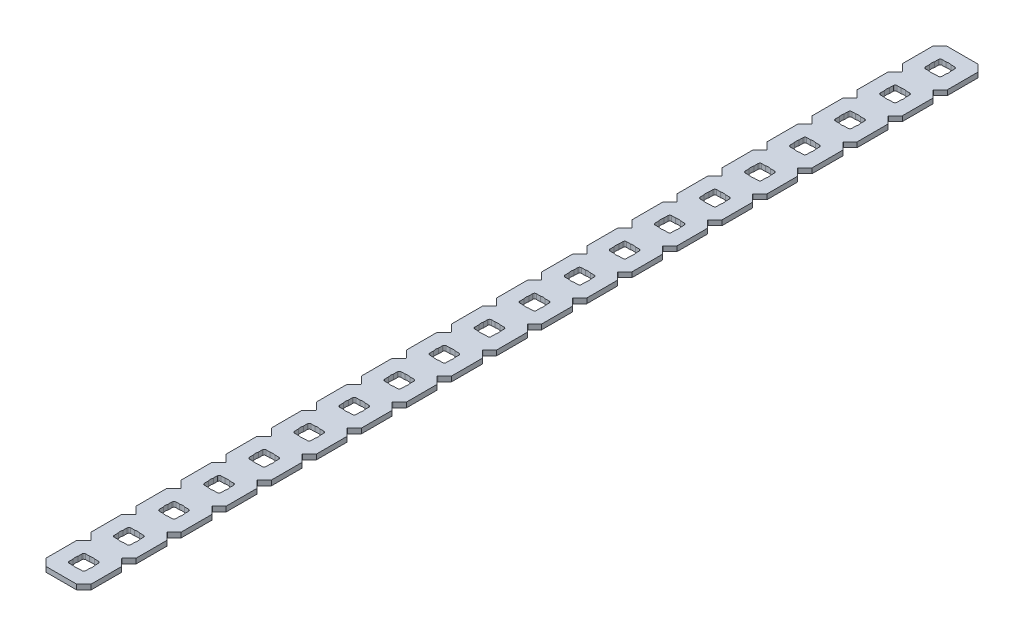
from build123d import *

# Parameters (mm, degrees)
BOSS_EXTRUDE1_DEPTH = 1.4224
SKETCH2_R           = 2.413
CUT_EXTRUDE1_DEPTH  = 2.54
LPATTERN1_COUNT     = 25
LPATTERN1_PITCH     = 12.7
SKETCH3_W           = 12.7
SKETCH3_H           = 63.589802561
CUT_EXTRUDE2_DEPTH  = 2.4224


with BuildPart() as part:
    # Sketch1 → Boss-Extrude1 (new body)
    with BuildSketch(Plane.XZ):
        with BuildLine():
            Line((12.7, -302.773014945), (12.7, -294.126985055))
            Line((12.7, -294.126985055), (10.762817506, -292.189802561))
            ThreePointArc((10.762817506, -292.189802561), (10.725620068, -292.1), (10.762817506, -292.010197439))
            Line((10.762817506, -292.010197439), (12.7, -290.073014945))
            Line((12.7, -290.073014945), (12.7, -281.426985055))
            Line((12.7, -281.426985055), (10.762817506, -279.489802561))
            ThreePointArc((10.762817506, -279.489802561), (10.725620068, -279.4), (10.762817506, -279.310197439))
            Line((10.762817506, -279.310197439), (12.7, -277.373014945))
            Line((12.7, -277.373014945), (12.7, -268.726985055))
            Line((12.7, -268.726985055), (10.762817506, -266.789802561))
            ThreePointArc((10.762817506, -266.789802561), (10.725620068, -266.7), (10.762817506, -266.610197439))
            Line((10.762817506, -266.610197439), (12.7, -264.673014945))
            Line((12.7, -264.673014945), (12.7, -256.026985055))
            Line((12.7, -256.026985055), (10.762817506, -254.089802561))
            ThreePointArc((10.762817506, -254.089802561), (10.725620068, -254), (10.762817506, -253.910197439))
            Line((10.762817506, -253.910197439), (12.7, -251.973014945))
            Line((12.7, -251.973014945), (12.7, -243.326985055))
            Line((12.7, -243.326985055), (10.762817506, -241.389802561))
            ThreePointArc((10.762817506, -241.389802561), (10.725620068, -241.3), (10.762817506, -241.210197439))
            Line((10.762817506, -241.210197439), (12.7, -239.273014945))
            Line((12.7, -239.273014945), (12.7, -230.626985055))
            Line((12.7, -230.626985055), (10.762817506, -228.689802561))
            ThreePointArc((10.762817506, -228.689802561), (10.725620068, -228.6), (10.762817506, -228.510197439))
            Line((10.762817506, -228.510197439), (12.7, -226.573014945))
            Line((12.7, -226.573014945), (12.7, -217.926985055))
            Line((12.7, -217.926985055), (10.762817506, -215.989802561))
            ThreePointArc((10.762817506, -215.989802561), (10.725620068, -215.9), (10.762817506, -215.810197439))
            Line((10.762817506, -215.810197439), (12.7, -213.873014945))
            Line((12.7, -213.873014945), (12.7, -205.226985055))
            Line((12.7, -205.226985055), (10.762817506, -203.289802561))
            ThreePointArc((10.762817506, -203.289802561), (10.725620068, -203.2), (10.762817506, -203.110197439))
            Line((10.762817506, -203.110197439), (12.7, -201.173014945))
            Line((12.7, -201.173014945), (12.7, -192.526985055))
            Line((12.7, -192.526985055), (10.762817506, -190.589802561))
            ThreePointArc((10.762817506, -190.589802561), (10.725620068, -190.5), (10.762817506, -190.410197439))
            Line((10.762817506, -190.410197439), (12.7, -188.473014945))
            Line((12.7, -188.473014945), (12.7, -179.826985055))
            Line((12.7, -179.826985055), (10.762817506, -177.889802561))
            ThreePointArc((10.762817506, -177.889802561), (10.725620068, -177.8), (10.762817506, -177.710197439))
            Line((10.762817506, -177.710197439), (12.7, -175.773014945))
            Line((12.7, -175.773014945), (12.7, -167.126985055))
            Line((12.7, -167.126985055), (10.762817506, -165.189802561))
            ThreePointArc((10.762817506, -165.189802561), (10.725620068, -165.1), (10.762817506, -165.010197439))
            Line((10.762817506, -165.010197439), (12.7, -163.073014945))
            Line((12.7, -163.073014945), (12.7, -154.426985055))
            Line((12.7, -154.426985055), (10.762817506, -152.489802561))
            ThreePointArc((10.762817506, -152.489802561), (10.725620068, -152.4), (10.762817506, -152.310197439))
            Line((10.762817506, -152.310197439), (12.7, -150.373014945))
            Line((12.7, -150.373014945), (12.7, -141.726985055))
            Line((12.7, -141.726985055), (10.762817506, -139.789802561))
            ThreePointArc((10.762817506, -139.789802561), (10.725620068, -139.7), (10.762817506, -139.610197439))
            Line((10.762817506, -139.610197439), (12.7, -137.673014945))
            Line((12.7, -137.673014945), (12.7, -129.026985055))
            Line((12.7, -129.026985055), (10.762817506, -127.089802561))
            ThreePointArc((10.762817506, -127.089802561), (10.725620068, -127), (10.762817506, -126.910197439))
            Line((10.762817506, -126.910197439), (12.7, -124.973014945))
            Line((12.7, -124.973014945), (12.7, -116.326985055))
            Line((12.7, -116.326985055), (10.762817506, -114.389802561))
            ThreePointArc((10.762817506, -114.389802561), (10.725620068, -114.3), (10.762817506, -114.210197439))
            Line((10.762817506, -114.210197439), (12.7, -112.273014945))
            Line((12.7, -112.273014945), (12.7, -103.626985055))
            Line((12.7, -103.626985055), (10.762817506, -101.689802561))
            ThreePointArc((10.762817506, -101.689802561), (10.725620068, -101.6), (10.762817506, -101.510197439))
            Line((10.762817506, -101.510197439), (12.7, -99.573014945))
            Line((12.7, -99.573014945), (12.7, -90.926985055))
            Line((12.7, -90.926985055), (10.762817506, -88.989802561))
            ThreePointArc((10.762817506, -88.989802561), (10.725620068, -88.9), (10.762817506, -88.810197439))
            Line((10.762817506, -88.810197439), (12.7, -86.873014945))
            Line((12.7, -86.873014945), (12.7, -78.226985055))
            Line((12.7, -78.226985055), (10.762817506, -76.289802561))
            ThreePointArc((10.762817506, -76.289802561), (10.725620068, -76.2), (10.762817506, -76.110197439))
            Line((10.762817506, -76.110197439), (12.7, -74.173014945))
            Line((12.7, -74.173014945), (12.7, -65.526985055))
            Line((12.7, -65.526985055), (10.762817506, -63.589802561))
            ThreePointArc((10.762817506, -63.589802561), (10.725620068, -63.5), (10.762817506, -63.410197439))
            Line((10.762817506, -63.410197439), (12.7, -61.473014945))
            Line((12.7, -61.473014945), (12.7, -52.826985055))
            Line((12.7, -52.826985055), (10.762817506, -50.889802561))
            ThreePointArc((10.762817506, -50.889802561), (10.725620068, -50.8), (10.762817506, -50.710197439))
            Line((10.762817506, -50.710197439), (12.7, -48.773014945))
            Line((12.7, -48.773014945), (12.7, -40.126985055))
            Line((12.7, -40.126985055), (10.762817506, -38.189802561))
            ThreePointArc((10.762817506, -38.189802561), (10.725620068, -38.1), (10.762817506, -38.010197439))
            Line((10.762817506, -38.010197439), (12.7, -36.073014945))
            Line((12.7, -36.073014945), (12.7, -27.426985055))
            Line((12.7, -27.426985055), (10.762817506, -25.489802561))
            ThreePointArc((10.762817506, -25.489802561), (10.725620068, -25.4), (10.762817506, -25.310197439))
            Line((10.762817506, -25.310197439), (12.7, -23.373014945))
            Line((12.7, -23.373014945), (12.7, -14.726985055))
            Line((12.7, -14.726985055), (10.762817506, -12.789802561))
            ThreePointArc((10.762817506, -12.789802561), (10.725620068, -12.7), (10.762817506, -12.610197439))
            Line((10.762817506, -12.610197439), (12.7, -10.673014945))
            Line((12.7, -10.673014945), (12.7, -2.032))
            Line((12.7, -2.032), (10.668, 0))
            Line((10.668, 0), (2.032, 0))
            Line((2.032, 0), (0, -2.032))
            Line((0, -2.032), (0, -10.673014945))
            Line((0, -10.673014945), (1.937182494, -12.610197439))
            ThreePointArc((1.937182494, -12.610197439), (1.974379932, -12.7), (1.937182494, -12.789802561))
            Line((1.937182494, -12.789802561), (0, -14.726985055))
            Line((0, -14.726985055), (0, -23.373014945))
            Line((0, -23.373014945), (1.937182494, -25.310197439))
            ThreePointArc((1.937182494, -25.310197439), (1.974379932, -25.4), (1.937182494, -25.489802561))
            Line((1.937182494, -25.489802561), (0, -27.426985055))
            Line((0, -27.426985055), (0, -36.073014945))
            Line((0, -36.073014945), (1.937182494, -38.010197439))
            ThreePointArc((1.937182494, -38.010197439), (1.974379932, -38.1), (1.937182494, -38.189802561))
            Line((1.937182494, -38.189802561), (0, -40.126985055))
            Line((0, -40.126985055), (0, -48.773014945))
            Line((0, -48.773014945), (1.937182494, -50.710197439))
            ThreePointArc((1.937182494, -50.710197439), (1.974379932, -50.8), (1.937182494, -50.889802561))
            Line((1.937182494, -50.889802561), (0, -52.826985055))
            Line((0, -52.826985055), (0, -61.473014945))
            Line((0, -61.473014945), (1.937182494, -63.410197439))
            ThreePointArc((1.937182494, -63.410197439), (1.974379932, -63.5), (1.937182494, -63.589802561))
            Line((1.937182494, -63.589802561), (0, -65.526985055))
            Line((0, -65.526985055), (0, -74.173014945))
            Line((0, -74.173014945), (1.937182494, -76.110197439))
            ThreePointArc((1.937182494, -76.110197439), (1.974379932, -76.2), (1.937182494, -76.289802561))
            Line((1.937182494, -76.289802561), (0, -78.226985055))
            Line((0, -78.226985055), (0, -86.873014945))
            Line((0, -86.873014945), (1.937182494, -88.810197439))
            ThreePointArc((1.937182494, -88.810197439), (1.974379932, -88.9), (1.937182494, -88.989802561))
            Line((1.937182494, -88.989802561), (0, -90.926985055))
            Line((0, -90.926985055), (0, -99.573014945))
            Line((0, -99.573014945), (1.937182494, -101.510197439))
            ThreePointArc((1.937182494, -101.510197439), (1.974379932, -101.6), (1.937182494, -101.689802561))
            Line((1.937182494, -101.689802561), (0, -103.626985055))
            Line((0, -103.626985055), (0, -112.273014945))
            Line((0, -112.273014945), (1.937182494, -114.210197439))
            ThreePointArc((1.937182494, -114.210197439), (1.974379932, -114.3), (1.937182494, -114.389802561))
            Line((1.937182494, -114.389802561), (0, -116.326985055))
            Line((0, -116.326985055), (0, -124.973014945))
            Line((0, -124.973014945), (1.937182494, -126.910197439))
            ThreePointArc((1.937182494, -126.910197439), (1.974379932, -127), (1.937182494, -127.089802561))
            Line((1.937182494, -127.089802561), (0, -129.026985055))
            Line((0, -129.026985055), (0, -137.673014945))
            Line((0, -137.673014945), (1.937182494, -139.610197439))
            ThreePointArc((1.937182494, -139.610197439), (1.974379932, -139.7), (1.937182494, -139.789802561))
            Line((1.937182494, -139.789802561), (0, -141.726985055))
            Line((0, -141.726985055), (0, -150.373014945))
            Line((0, -150.373014945), (1.937182494, -152.310197439))
            ThreePointArc((1.937182494, -152.310197439), (1.974379932, -152.4), (1.937182494, -152.489802561))
            Line((1.937182494, -152.489802561), (0, -154.426985055))
            Line((0, -154.426985055), (0, -163.073014945))
            Line((0, -163.073014945), (1.937182494, -165.010197439))
            ThreePointArc((1.937182494, -165.010197439), (1.974379932, -165.1), (1.937182494, -165.189802561))
            Line((1.937182494, -165.189802561), (0, -167.126985055))
            Line((0, -167.126985055), (0, -175.773014945))
            Line((0, -175.773014945), (1.937182494, -177.710197439))
            ThreePointArc((1.937182494, -177.710197439), (1.974379932, -177.8), (1.937182494, -177.889802561))
            Line((1.937182494, -177.889802561), (0, -179.826985055))
            Line((0, -179.826985055), (0, -188.473014945))
            Line((0, -188.473014945), (1.937182494, -190.410197439))
            ThreePointArc((1.937182494, -190.410197439), (1.974379932, -190.5), (1.937182494, -190.589802561))
            Line((1.937182494, -190.589802561), (0, -192.526985055))
            Line((0, -192.526985055), (0, -201.173014945))
            Line((0, -201.173014945), (1.937182494, -203.110197439))
            ThreePointArc((1.937182494, -203.110197439), (1.974379932, -203.2), (1.937182494, -203.289802561))
            Line((1.937182494, -203.289802561), (0, -205.226985055))
            Line((0, -205.226985055), (0, -213.873014945))
            Line((0, -213.873014945), (1.937182494, -215.810197439))
            ThreePointArc((1.937182494, -215.810197439), (1.974379932, -215.9), (1.937182494, -215.989802561))
            Line((1.937182494, -215.989802561), (0, -217.926985055))
            Line((0, -217.926985055), (0, -226.573014945))
            Line((0, -226.573014945), (1.937182494, -228.510197439))
            ThreePointArc((1.937182494, -228.510197439), (1.974379932, -228.6), (1.937182494, -228.689802561))
            Line((1.937182494, -228.689802561), (0, -230.626985055))
            Line((0, -230.626985055), (0, -239.273014945))
            Line((0, -239.273014945), (1.937182494, -241.210197439))
            ThreePointArc((1.937182494, -241.210197439), (1.974379932, -241.3), (1.937182494, -241.389802561))
            Line((1.937182494, -241.389802561), (0, -243.326985055))
            Line((0, -243.326985055), (0, -251.973014945))
            Line((0, -251.973014945), (1.937182494, -253.910197439))
            ThreePointArc((1.937182494, -253.910197439), (1.974379932, -254), (1.937182494, -254.089802561))
            Line((1.937182494, -254.089802561), (0, -256.026985055))
            Line((0, -256.026985055), (0, -264.673014945))
            Line((0, -264.673014945), (1.937182494, -266.610197439))
            ThreePointArc((1.937182494, -266.610197439), (1.974379932, -266.7), (1.937182494, -266.789802561))
            Line((1.937182494, -266.789802561), (0, -268.726985055))
            Line((0, -268.726985055), (0, -277.373014945))
            Line((0, -277.373014945), (1.937182494, -279.310197439))
            ThreePointArc((1.937182494, -279.310197439), (1.974379932, -279.4), (1.937182494, -279.489802561))
            Line((1.937182494, -279.489802561), (0, -281.426985055))
            Line((0, -281.426985055), (0, -290.073014945))
            Line((0, -290.073014945), (1.937182494, -292.010197439))
            ThreePointArc((1.937182494, -292.010197439), (1.974379932, -292.1), (1.937182494, -292.189802561))
            Line((1.937182494, -292.189802561), (0, -294.126985055))
            Line((0, -294.126985055), (0, -302.773014945))
            Line((0, -302.773014945), (1.937182494, -304.710197439))
            ThreePointArc((1.937182494, -304.710197439), (1.974379932, -304.8), (1.937182494, -304.889802561))
            Line((1.937182494, -304.889802561), (0, -306.826985055))
            Line((0, -306.826985055), (0, -315.468))
            Line((0, -315.468), (2.032, -317.5))
            Line((2.032, -317.5), (10.668, -317.5))
            Line((10.668, -317.5), (12.7, -315.468))
            Line((12.7, -315.468), (12.7, -306.826985055))
            Line((12.7, -306.826985055), (10.762817506, -304.889802561))
            ThreePointArc((10.762817506, -304.889802561), (10.725620068, -304.8), (10.762817506, -304.710197439))
            Line((10.762817506, -304.710197439), (12.7, -302.773014945))
        make_face()
        with BuildLine():
            Line((4.5466, -308.8386), (8.1534, -308.8386))
            ThreePointArc((8.1534, -308.8386), (8.512610245, -308.987389755), (8.6614, -309.3466))
            Line((8.6614, -309.3466), (8.6614, -312.9534))
            ThreePointArc((8.6614, -312.9534), (8.512610245, -313.312610245), (8.1534, -313.4614))
            Line((8.1534, -313.4614), (4.5466, -313.4614))
            ThreePointArc((4.5466, -313.4614), (4.187389755, -313.312610245), (4.0386, -312.9534))
            Line((4.0386, -312.9534), (4.0386, -309.3466))
            ThreePointArc((4.0386, -309.3466), (4.187389755, -308.987389755), (4.5466, -308.8386))
        make_face(mode=Mode.SUBTRACT)
        with BuildLine():
            Line((4.5466, -296.1386), (8.1534, -296.1386))
            ThreePointArc((8.1534, -296.1386), (8.512610245, -296.287389755), (8.6614, -296.6466))
            Line((8.6614, -296.6466), (8.6614, -300.2534))
            ThreePointArc((8.6614, -300.2534), (8.512610245, -300.612610245), (8.1534, -300.7614))
            Line((8.1534, -300.7614), (4.5466, -300.7614))
            ThreePointArc((4.5466, -300.7614), (4.187389755, -300.612610245), (4.0386, -300.2534))
            Line((4.0386, -300.2534), (4.0386, -296.6466))
            ThreePointArc((4.0386, -296.6466), (4.187389755, -296.287389755), (4.5466, -296.1386))
        make_face(mode=Mode.SUBTRACT)
        with BuildLine():
            Line((4.5466, -283.4386), (8.1534, -283.4386))
            ThreePointArc((8.1534, -283.4386), (8.512610245, -283.587389755), (8.6614, -283.9466))
            Line((8.6614, -283.9466), (8.6614, -287.5534))
            ThreePointArc((8.6614, -287.5534), (8.512610245, -287.912610245), (8.1534, -288.0614))
            Line((8.1534, -288.0614), (4.5466, -288.0614))
            ThreePointArc((4.5466, -288.0614), (4.187389755, -287.912610245), (4.0386, -287.5534))
            Line((4.0386, -287.5534), (4.0386, -283.9466))
            ThreePointArc((4.0386, -283.9466), (4.187389755, -283.587389755), (4.5466, -283.4386))
        make_face(mode=Mode.SUBTRACT)
        with BuildLine():
            Line((4.5466, -270.7386), (8.1534, -270.7386))
            ThreePointArc((8.1534, -270.7386), (8.512610245, -270.887389755), (8.6614, -271.2466))
            Line((8.6614, -271.2466), (8.6614, -274.8534))
            ThreePointArc((8.6614, -274.8534), (8.512610245, -275.212610245), (8.1534, -275.3614))
            Line((8.1534, -275.3614), (4.5466, -275.3614))
            ThreePointArc((4.5466, -275.3614), (4.187389755, -275.212610245), (4.0386, -274.8534))
            Line((4.0386, -274.8534), (4.0386, -271.2466))
            ThreePointArc((4.0386, -271.2466), (4.187389755, -270.887389755), (4.5466, -270.7386))
        make_face(mode=Mode.SUBTRACT)
        with BuildLine():
            Line((4.5466, -258.0386), (8.1534, -258.0386))
            ThreePointArc((8.1534, -258.0386), (8.512610245, -258.187389755), (8.6614, -258.5466))
            Line((8.6614, -258.5466), (8.6614, -262.1534))
            ThreePointArc((8.6614, -262.1534), (8.512610245, -262.512610245), (8.1534, -262.6614))
            Line((8.1534, -262.6614), (4.5466, -262.6614))
            ThreePointArc((4.5466, -262.6614), (4.187389755, -262.512610245), (4.0386, -262.1534))
            Line((4.0386, -262.1534), (4.0386, -258.5466))
            ThreePointArc((4.0386, -258.5466), (4.187389755, -258.187389755), (4.5466, -258.0386))
        make_face(mode=Mode.SUBTRACT)
        with BuildLine():
            Line((4.5466, -245.3386), (8.1534, -245.3386))
            ThreePointArc((8.1534, -245.3386), (8.512610245, -245.487389755), (8.6614, -245.8466))
            Line((8.6614, -245.8466), (8.6614, -249.4534))
            ThreePointArc((8.6614, -249.4534), (8.512610245, -249.812610245), (8.1534, -249.9614))
            Line((8.1534, -249.9614), (4.5466, -249.9614))
            ThreePointArc((4.5466, -249.9614), (4.187389755, -249.812610245), (4.0386, -249.4534))
            Line((4.0386, -249.4534), (4.0386, -245.8466))
            ThreePointArc((4.0386, -245.8466), (4.187389755, -245.487389755), (4.5466, -245.3386))
        make_face(mode=Mode.SUBTRACT)
        with BuildLine():
            Line((4.5466, -232.6386), (8.1534, -232.6386))
            ThreePointArc((8.1534, -232.6386), (8.512610245, -232.787389755), (8.6614, -233.1466))
            Line((8.6614, -233.1466), (8.6614, -236.7534))
            ThreePointArc((8.6614, -236.7534), (8.512610245, -237.112610245), (8.1534, -237.2614))
            Line((8.1534, -237.2614), (4.5466, -237.2614))
            ThreePointArc((4.5466, -237.2614), (4.187389755, -237.112610245), (4.0386, -236.7534))
            Line((4.0386, -236.7534), (4.0386, -233.1466))
            ThreePointArc((4.0386, -233.1466), (4.187389755, -232.787389755), (4.5466, -232.6386))
        make_face(mode=Mode.SUBTRACT)
        with BuildLine():
            Line((4.5466, -219.9386), (8.1534, -219.9386))
            ThreePointArc((8.1534, -219.9386), (8.512610245, -220.087389755), (8.6614, -220.4466))
            Line((8.6614, -220.4466), (8.6614, -224.0534))
            ThreePointArc((8.6614, -224.0534), (8.512610245, -224.412610245), (8.1534, -224.5614))
            Line((8.1534, -224.5614), (4.5466, -224.5614))
            ThreePointArc((4.5466, -224.5614), (4.187389755, -224.412610245), (4.0386, -224.0534))
            Line((4.0386, -224.0534), (4.0386, -220.4466))
            ThreePointArc((4.0386, -220.4466), (4.187389755, -220.087389755), (4.5466, -219.9386))
        make_face(mode=Mode.SUBTRACT)
        with BuildLine():
            Line((4.5466, -207.2386), (8.1534, -207.2386))
            ThreePointArc((8.1534, -207.2386), (8.512610245, -207.387389755), (8.6614, -207.7466))
            Line((8.6614, -207.7466), (8.6614, -211.3534))
            ThreePointArc((8.6614, -211.3534), (8.512610245, -211.712610245), (8.1534, -211.8614))
            Line((8.1534, -211.8614), (4.5466, -211.8614))
            ThreePointArc((4.5466, -211.8614), (4.187389755, -211.712610245), (4.0386, -211.3534))
            Line((4.0386, -211.3534), (4.0386, -207.7466))
            ThreePointArc((4.0386, -207.7466), (4.187389755, -207.387389755), (4.5466, -207.2386))
        make_face(mode=Mode.SUBTRACT)
        with BuildLine():
            Line((4.5466, -194.5386), (8.1534, -194.5386))
            ThreePointArc((8.1534, -194.5386), (8.512610245, -194.687389755), (8.6614, -195.0466))
            Line((8.6614, -195.0466), (8.6614, -198.6534))
            ThreePointArc((8.6614, -198.6534), (8.512610245, -199.012610245), (8.1534, -199.1614))
            Line((8.1534, -199.1614), (4.5466, -199.1614))
            ThreePointArc((4.5466, -199.1614), (4.187389755, -199.012610245), (4.0386, -198.6534))
            Line((4.0386, -198.6534), (4.0386, -195.0466))
            ThreePointArc((4.0386, -195.0466), (4.187389755, -194.687389755), (4.5466, -194.5386))
        make_face(mode=Mode.SUBTRACT)
        with BuildLine():
            Line((4.5466, -181.8386), (8.1534, -181.8386))
            ThreePointArc((8.1534, -181.8386), (8.512610245, -181.987389755), (8.6614, -182.3466))
            Line((8.6614, -182.3466), (8.6614, -185.9534))
            ThreePointArc((8.6614, -185.9534), (8.512610245, -186.312610245), (8.1534, -186.4614))
            Line((8.1534, -186.4614), (4.5466, -186.4614))
            ThreePointArc((4.5466, -186.4614), (4.187389755, -186.312610245), (4.0386, -185.9534))
            Line((4.0386, -185.9534), (4.0386, -182.3466))
            ThreePointArc((4.0386, -182.3466), (4.187389755, -181.987389755), (4.5466, -181.8386))
        make_face(mode=Mode.SUBTRACT)
        with BuildLine():
            Line((4.5466, -169.1386), (8.1534, -169.1386))
            ThreePointArc((8.1534, -169.1386), (8.512610245, -169.287389755), (8.6614, -169.6466))
            Line((8.6614, -169.6466), (8.6614, -173.2534))
            ThreePointArc((8.6614, -173.2534), (8.512610245, -173.612610245), (8.1534, -173.7614))
            Line((8.1534, -173.7614), (4.5466, -173.7614))
            ThreePointArc((4.5466, -173.7614), (4.187389755, -173.612610245), (4.0386, -173.2534))
            Line((4.0386, -173.2534), (4.0386, -169.6466))
            ThreePointArc((4.0386, -169.6466), (4.187389755, -169.287389755), (4.5466, -169.1386))
        make_face(mode=Mode.SUBTRACT)
        with BuildLine():
            Line((4.5466, -156.4386), (8.1534, -156.4386))
            ThreePointArc((8.1534, -156.4386), (8.512610245, -156.587389755), (8.6614, -156.9466))
            Line((8.6614, -156.9466), (8.6614, -160.5534))
            ThreePointArc((8.6614, -160.5534), (8.512610245, -160.912610245), (8.1534, -161.0614))
            Line((8.1534, -161.0614), (4.5466, -161.0614))
            ThreePointArc((4.5466, -161.0614), (4.187389755, -160.912610245), (4.0386, -160.5534))
            Line((4.0386, -160.5534), (4.0386, -156.9466))
            ThreePointArc((4.0386, -156.9466), (4.187389755, -156.587389755), (4.5466, -156.4386))
        make_face(mode=Mode.SUBTRACT)
        with BuildLine():
            Line((4.5466, -143.7386), (8.1534, -143.7386))
            ThreePointArc((8.1534, -143.7386), (8.512610245, -143.887389755), (8.6614, -144.2466))
            Line((8.6614, -144.2466), (8.6614, -147.8534))
            ThreePointArc((8.6614, -147.8534), (8.512610245, -148.212610245), (8.1534, -148.3614))
            Line((8.1534, -148.3614), (4.5466, -148.3614))
            ThreePointArc((4.5466, -148.3614), (4.187389755, -148.212610245), (4.0386, -147.8534))
            Line((4.0386, -147.8534), (4.0386, -144.2466))
            ThreePointArc((4.0386, -144.2466), (4.187389755, -143.887389755), (4.5466, -143.7386))
        make_face(mode=Mode.SUBTRACT)
        with BuildLine():
            Line((4.5466, -131.0386), (8.1534, -131.0386))
            ThreePointArc((8.1534, -131.0386), (8.512610245, -131.187389755), (8.6614, -131.5466))
            Line((8.6614, -131.5466), (8.6614, -135.1534))
            ThreePointArc((8.6614, -135.1534), (8.512610245, -135.512610245), (8.1534, -135.6614))
            Line((8.1534, -135.6614), (4.5466, -135.6614))
            ThreePointArc((4.5466, -135.6614), (4.187389755, -135.512610245), (4.0386, -135.1534))
            Line((4.0386, -135.1534), (4.0386, -131.5466))
            ThreePointArc((4.0386, -131.5466), (4.187389755, -131.187389755), (4.5466, -131.0386))
        make_face(mode=Mode.SUBTRACT)
        with BuildLine():
            Line((4.5466, -118.3386), (8.1534, -118.3386))
            ThreePointArc((8.1534, -118.3386), (8.512610245, -118.487389755), (8.6614, -118.8466))
            Line((8.6614, -118.8466), (8.6614, -122.4534))
            ThreePointArc((8.6614, -122.4534), (8.512610245, -122.812610245), (8.1534, -122.9614))
            Line((8.1534, -122.9614), (4.5466, -122.9614))
            ThreePointArc((4.5466, -122.9614), (4.187389755, -122.812610245), (4.0386, -122.4534))
            Line((4.0386, -122.4534), (4.0386, -118.8466))
            ThreePointArc((4.0386, -118.8466), (4.187389755, -118.487389755), (4.5466, -118.3386))
        make_face(mode=Mode.SUBTRACT)
        with BuildLine():
            Line((4.5466, -105.6386), (8.1534, -105.6386))
            ThreePointArc((8.1534, -105.6386), (8.512610245, -105.787389755), (8.6614, -106.1466))
            Line((8.6614, -106.1466), (8.6614, -109.7534))
            ThreePointArc((8.6614, -109.7534), (8.512610245, -110.112610245), (8.1534, -110.2614))
            Line((8.1534, -110.2614), (4.5466, -110.2614))
            ThreePointArc((4.5466, -110.2614), (4.187389755, -110.112610245), (4.0386, -109.7534))
            Line((4.0386, -109.7534), (4.0386, -106.1466))
            ThreePointArc((4.0386, -106.1466), (4.187389755, -105.787389755), (4.5466, -105.6386))
        make_face(mode=Mode.SUBTRACT)
        with BuildLine():
            Line((4.5466, -92.9386), (8.1534, -92.9386))
            ThreePointArc((8.1534, -92.9386), (8.512610245, -93.087389755), (8.6614, -93.4466))
            Line((8.6614, -93.4466), (8.6614, -97.0534))
            ThreePointArc((8.6614, -97.0534), (8.512610245, -97.412610245), (8.1534, -97.5614))
            Line((8.1534, -97.5614), (4.5466, -97.5614))
            ThreePointArc((4.5466, -97.5614), (4.187389755, -97.412610245), (4.0386, -97.0534))
            Line((4.0386, -97.0534), (4.0386, -93.4466))
            ThreePointArc((4.0386, -93.4466), (4.187389755, -93.087389755), (4.5466, -92.9386))
        make_face(mode=Mode.SUBTRACT)
        with BuildLine():
            Line((4.5466, -80.2386), (8.1534, -80.2386))
            ThreePointArc((8.1534, -80.2386), (8.512610245, -80.387389755), (8.6614, -80.7466))
            Line((8.6614, -80.7466), (8.6614, -84.3534))
            ThreePointArc((8.6614, -84.3534), (8.512610245, -84.712610245), (8.1534, -84.8614))
            Line((8.1534, -84.8614), (4.5466, -84.8614))
            ThreePointArc((4.5466, -84.8614), (4.187389755, -84.712610245), (4.0386, -84.3534))
            Line((4.0386, -84.3534), (4.0386, -80.7466))
            ThreePointArc((4.0386, -80.7466), (4.187389755, -80.387389755), (4.5466, -80.2386))
        make_face(mode=Mode.SUBTRACT)
        with BuildLine():
            Line((4.5466, -67.5386), (8.1534, -67.5386))
            ThreePointArc((8.1534, -67.5386), (8.512610245, -67.687389755), (8.6614, -68.0466))
            Line((8.6614, -68.0466), (8.6614, -71.6534))
            ThreePointArc((8.6614, -71.6534), (8.512610245, -72.012610245), (8.1534, -72.1614))
            Line((8.1534, -72.1614), (4.5466, -72.1614))
            ThreePointArc((4.5466, -72.1614), (4.187389755, -72.012610245), (4.0386, -71.6534))
            Line((4.0386, -71.6534), (4.0386, -68.0466))
            ThreePointArc((4.0386, -68.0466), (4.187389755, -67.687389755), (4.5466, -67.5386))
        make_face(mode=Mode.SUBTRACT)
        with BuildLine():
            Line((4.5466, -54.8386), (8.1534, -54.8386))
            ThreePointArc((8.1534, -54.8386), (8.512610245, -54.987389755), (8.6614, -55.3466))
            Line((8.6614, -55.3466), (8.6614, -58.9534))
            ThreePointArc((8.6614, -58.9534), (8.512610245, -59.312610245), (8.1534, -59.4614))
            Line((8.1534, -59.4614), (4.5466, -59.4614))
            ThreePointArc((4.5466, -59.4614), (4.187389755, -59.312610245), (4.0386, -58.9534))
            Line((4.0386, -58.9534), (4.0386, -55.3466))
            ThreePointArc((4.0386, -55.3466), (4.187389755, -54.987389755), (4.5466, -54.8386))
        make_face(mode=Mode.SUBTRACT)
        with BuildLine():
            Line((4.5466, -42.1386), (8.1534, -42.1386))
            ThreePointArc((8.1534, -42.1386), (8.512610245, -42.287389755), (8.6614, -42.6466))
            Line((8.6614, -42.6466), (8.6614, -46.2534))
            ThreePointArc((8.6614, -46.2534), (8.512610245, -46.612610245), (8.1534, -46.7614))
            Line((8.1534, -46.7614), (4.5466, -46.7614))
            ThreePointArc((4.5466, -46.7614), (4.187389755, -46.612610245), (4.0386, -46.2534))
            Line((4.0386, -46.2534), (4.0386, -42.6466))
            ThreePointArc((4.0386, -42.6466), (4.187389755, -42.287389755), (4.5466, -42.1386))
        make_face(mode=Mode.SUBTRACT)
        with BuildLine():
            Line((4.5466, -29.4386), (8.1534, -29.4386))
            ThreePointArc((8.1534, -29.4386), (8.512610245, -29.587389755), (8.6614, -29.9466))
            Line((8.6614, -29.9466), (8.6614, -33.5534))
            ThreePointArc((8.6614, -33.5534), (8.512610245, -33.912610245), (8.1534, -34.0614))
            Line((8.1534, -34.0614), (4.5466, -34.0614))
            ThreePointArc((4.5466, -34.0614), (4.187389755, -33.912610245), (4.0386, -33.5534))
            Line((4.0386, -33.5534), (4.0386, -29.9466))
            ThreePointArc((4.0386, -29.9466), (4.187389755, -29.587389755), (4.5466, -29.4386))
        make_face(mode=Mode.SUBTRACT)
        with BuildLine():
            Line((8.1534, -8.6614), (4.5466, -8.6614))
            ThreePointArc((4.5466, -8.6614), (4.187389755, -8.512610245), (4.0386, -8.1534))
            Line((4.0386, -8.1534), (4.0386, -4.5466))
            ThreePointArc((4.0386, -4.5466), (4.187389755, -4.187389755), (4.5466, -4.0386))
            Line((4.5466, -4.0386), (8.1534, -4.0386))
            ThreePointArc((8.1534, -4.0386), (8.512610245, -4.187389755), (8.6614, -4.5466))
            Line((8.6614, -4.5466), (8.6614, -8.1534))
            ThreePointArc((8.6614, -8.1534), (8.512610245, -8.512610245), (8.1534, -8.6614))
        make_face(mode=Mode.SUBTRACT)
        with BuildLine():
            Line((4.0386, -20.8534), (4.0386, -17.2466))
            ThreePointArc((4.0386, -17.2466), (4.187389755, -16.887389755), (4.5466, -16.7386))
            Line((4.5466, -16.7386), (8.1534, -16.7386))
            ThreePointArc((8.1534, -16.7386), (8.512610245, -16.887389755), (8.6614, -17.2466))
            Line((8.6614, -17.2466), (8.6614, -20.8534))
            ThreePointArc((8.6614, -20.8534), (8.512610245, -21.212610245), (8.1534, -21.3614))
            Line((8.1534, -21.3614), (4.5466, -21.3614))
            ThreePointArc((4.5466, -21.3614), (4.187389755, -21.212610245), (4.0386, -20.8534))
        make_face(mode=Mode.SUBTRACT)
    extrude(amount=-BOSS_EXTRUDE1_DEPTH)

    # Sketch2 → Cut-Extrude1 (cut)
    with BuildSketch(Plane(origin=(0, 1.4224, 0), x_dir=(1, 0, 0), z_dir=(0, 1, 0))):
        with Locations((6.35, 6.35)):
            Circle(SKETCH2_R)
    cut_extrude1 = extrude(amount=-CUT_EXTRUDE1_DEPTH, mode=Mode.SUBTRACT)

    # LPattern1: Cut-Extrude1 ×25
    with Locations(*[(0, 0, -i * LPATTERN1_PITCH) for i in range(1, LPATTERN1_COUNT)]):
        add(cut_extrude1, mode=Mode.SUBTRACT)

    # Sketch3 → Cut-Extrude2 (cut, through all)
    with BuildSketch(Plane(origin=(0, 1.4224, 0), x_dir=(1, 0, 0), z_dir=(0, 1, 0))):
        with Locations((6.35, 285.70509872)):
            Rectangle(SKETCH3_W, SKETCH3_H)
    extrude(amount=-CUT_EXTRUDE2_DEPTH, mode=Mode.SUBTRACT)


solid = part.part
